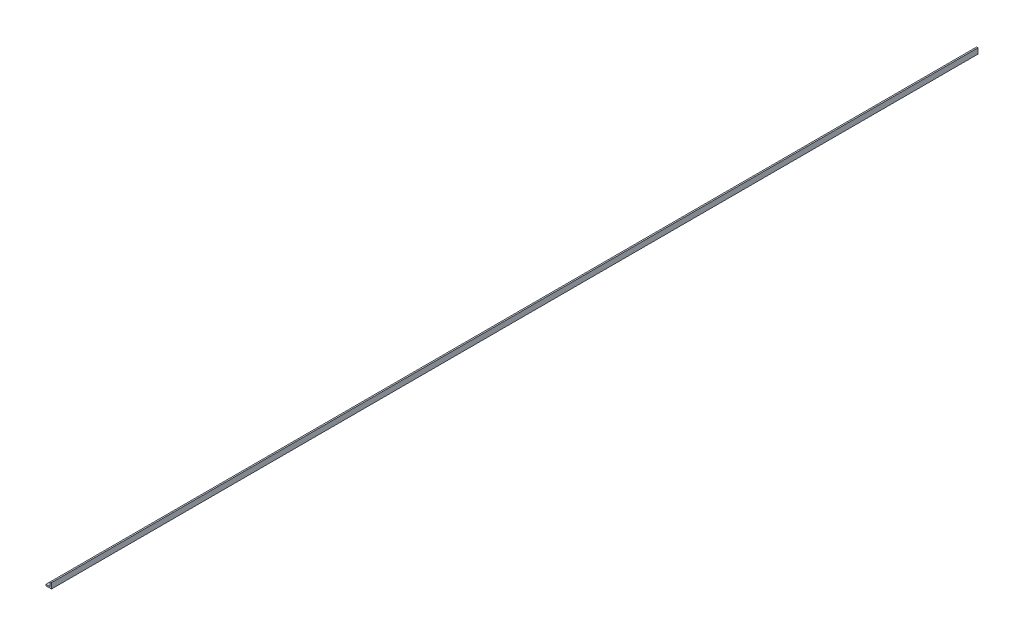
from build123d import *

# Parameters (mm, degrees)
BOSS_EXTRUDE1_DEPTH = 1066.8


with BuildPart() as part:
    # Sketch2 → Boss-Extrude1 (new body, symmetric)
    with BuildSketch(Plane.XY):
        Polygon((-6.35, 0), (6.35, 0), (6.35, 12.7), (3.175, 12.7), (3.175, 3.175), (-6.35, 3.175), align=None)
    extrude(amount=BOSS_EXTRUDE1_DEPTH, both=True)


solid = part.part
